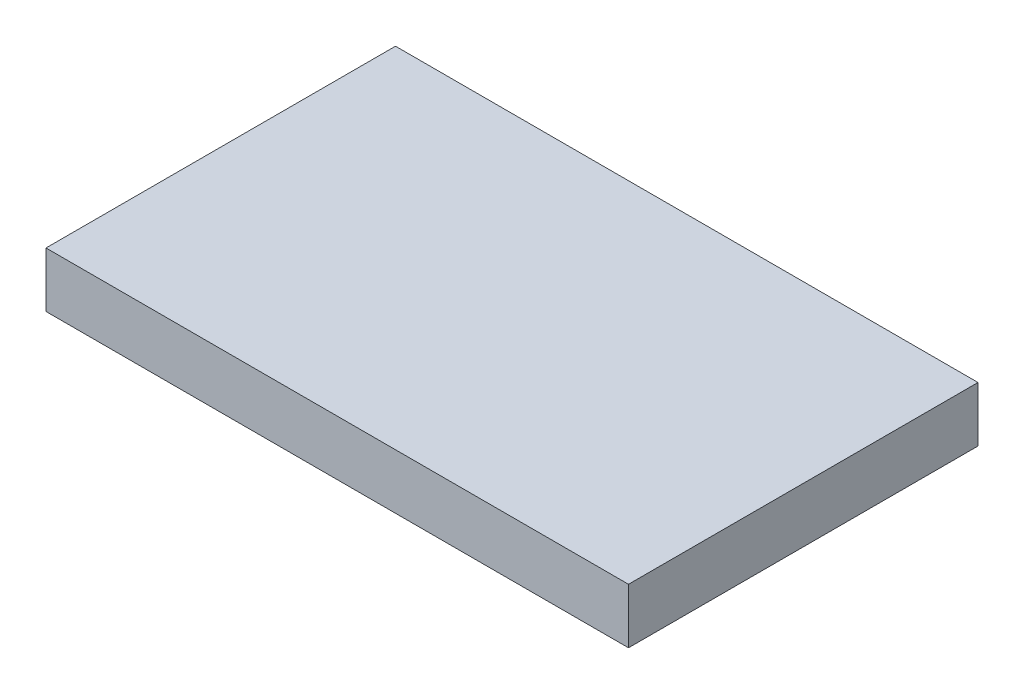
from build123d import *

# Parameters (mm, degrees)
SKETCH1_W           = 31.75
SKETCH1_H           = 19.05
BOSS_EXTRUDE1_DEPTH = 3


with BuildPart() as part:
    # Sketch1 → Boss-Extrude1 (new body)
    with BuildSketch(Plane(origin=(0, 0, 0), x_dir=(1, 0, 0), z_dir=(0, 1, 0))):
        Rectangle(SKETCH1_W, SKETCH1_H)
    extrude(amount=BOSS_EXTRUDE1_DEPTH)


solid = part.part
